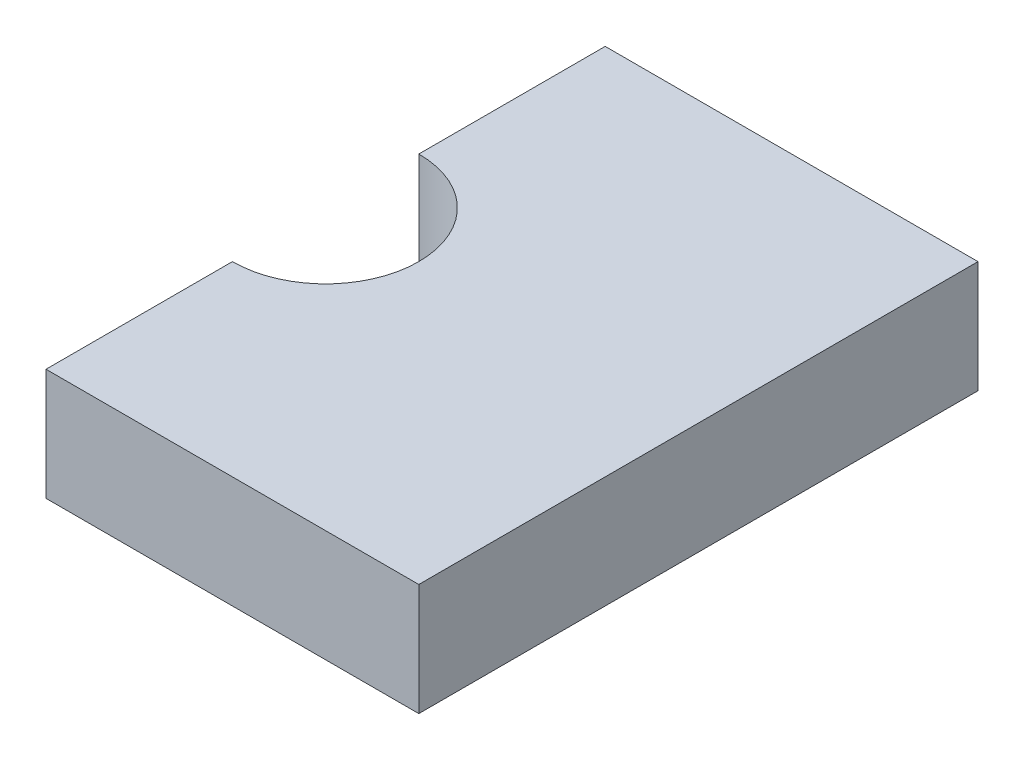
from build123d import *

# Parameters (mm, degrees)
EXTRUDE_1_DEPTH = 3


with BuildPart() as part:
    # Эскиз1 → Бобышка-Вытянуть1 (new body)
    with BuildSketch(Plane(origin=(0, 0, 0), x_dir=(1, 0, 0), z_dir=(0, 1, 0))):
        with BuildLine():
            Line((0, 15), (0, 10))
            ThreePointArc((0, 10), (2.5, 7.5), (0, 5))
            Line((0, 5), (0, 0))
            Line((0, 0), (10, 0))
            Line((10, 0), (10, 15))
            Line((10, 15), (0, 15))
        make_face()
    extrude(amount=EXTRUDE_1_DEPTH)


solid = part.part
